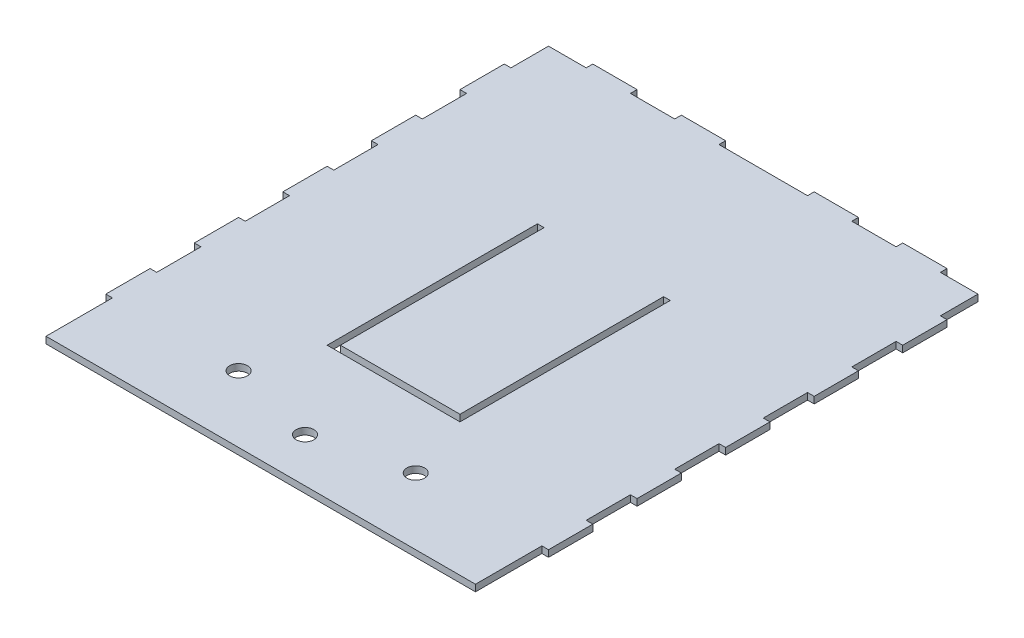
from build123d import *

# Parameters (mm, degrees)
SKETCH1_W           = 200
SKETCH1_H           = 230
BOSS_EXTRUDE1_DEPTH = 3
CUT_EXTRUDE2_DEPTH  = 3
SKETCH5_W           = 3
SKETCH5_H           = 20
SKETCH5_W_2         = 20
SKETCH5_H_2         = 3
SKETCH5_W_3         = 40
CUT_EXTRUDE4_DEPTH  = 3
SKETCH6_W           = 3
SKETCH6_H           = 5
BOSS_EXTRUDE2_DEPTH = 3
SKETCH7_W           = 3
SKETCH7_H           = 10
CUT_EXTRUDE5_DEPTH  = 3
SKETCH8_R           = 4
CUT_EXTRUDE6_DEPTH  = 3


with BuildPart() as part:
    # Sketch1 → Boss-Extrude1 (new body)
    with BuildSketch(Plane(origin=(0, 0, 0), x_dir=(1, 0, 0), z_dir=(0, 1, 0))):
        with Locations((0, -25)):
            Rectangle(SKETCH1_W, SKETCH1_H)
    extrude(amount=BOSS_EXTRUDE1_DEPTH)

    # Sketch2 → Cut-Extrude2 (cut)
    with BuildSketch(Plane(origin=(0, 3, 0), x_dir=(1, 0, 0), z_dir=(0, 1, 0))):
        Polygon((-30, -80), (30, -80), (30, 20), (27, 20), (27, -77), (-27, -77), (-27, 20), (-30, 20), align=None)
    extrude(amount=-CUT_EXTRUDE2_DEPTH, mode=Mode.SUBTRACT)

    # Sketch5 → Cut-Extrude4 (cut)
    with BuildSketch(Plane(origin=(0, 3, 0), x_dir=(1, 0, 0), z_dir=(0, 1, 0))):
        with Locations((98.5, -120)):
            Rectangle(SKETCH5_W, SKETCH5_H)
        Polygon((100, 90), (80, 90), (80, 87), (97, 87), (97, 70), (100, 70), align=None)
        Polygon((-100, 90), (-100, 70), (-97, 70), (-97, 87), (-80, 87), (-80, 90), align=None)
        with Locations((98.5, 40)):
            Rectangle(SKETCH5_W, SKETCH5_H)
        with Locations((98.5, 0)):
            Rectangle(SKETCH5_W, SKETCH5_H)
        with Locations((98.5, -40)):
            Rectangle(SKETCH5_W, SKETCH5_H)
        with Locations((98.5, -80)):
            Rectangle(SKETCH5_W, SKETCH5_H)
        with Locations((-98.5, 40)):
            Rectangle(SKETCH5_W, SKETCH5_H)
        with Locations((-98.5, 0)):
            Rectangle(SKETCH5_W, SKETCH5_H)
        with Locations((-98.5, -40)):
            Rectangle(SKETCH5_W, SKETCH5_H)
        with Locations((-98.5, -80)):
            Rectangle(SKETCH5_W, SKETCH5_H)
        with Locations((-98.5, -120)):
            Rectangle(SKETCH5_W, SKETCH5_H)
        with Locations((50, 88.5)):
            Rectangle(SKETCH5_W_2, SKETCH5_H_2)
        with Locations((0, 88.5)):
            Rectangle(SKETCH5_W_3, SKETCH5_H_2)
        with Locations((-50, 88.5)):
            Rectangle(SKETCH5_W_2, SKETCH5_H_2)
    extrude(amount=-CUT_EXTRUDE4_DEPTH, mode=Mode.SUBTRACT)

    # Sketch6 → Boss-Extrude2 (add)
    with BuildSketch(Plane(origin=(0, 3, 0), x_dir=(1, 0, 0), z_dir=(0, 1, 0))):
        with Locations((28.5, 17.5)):
            Rectangle(SKETCH6_W, SKETCH6_H)
        with Locations((-28.5, 17.5)):
            Rectangle(SKETCH6_W, SKETCH6_H)
    extrude(amount=-BOSS_EXTRUDE2_DEPTH)

    # Sketch7 → Cut-Extrude5 (cut)
    with BuildSketch(Plane(origin=(0, 3, 0), x_dir=(1, 0, 0), z_dir=(0, 1, 0))):
        with Locations((98.5, -135)):
            Rectangle(SKETCH7_W, SKETCH7_H)
        with Locations((-98.5, -135)):
            Rectangle(SKETCH7_W, SKETCH7_H)
    extrude(amount=-CUT_EXTRUDE5_DEPTH, mode=Mode.SUBTRACT)

    # Sketch8 → Cut-Extrude6 (cut)
    with BuildSketch(Plane(origin=(0, 3, 0), x_dir=(1, 0, 0), z_dir=(0, 1, 0))):
        with Locations((0, -120)):
            Circle(SKETCH8_R)
        with Locations((40, -110)):
            Circle(SKETCH8_R)
        with Locations((-40, -110)):
            Circle(SKETCH8_R)
    extrude(amount=-CUT_EXTRUDE6_DEPTH, mode=Mode.SUBTRACT)


solid = part.part
